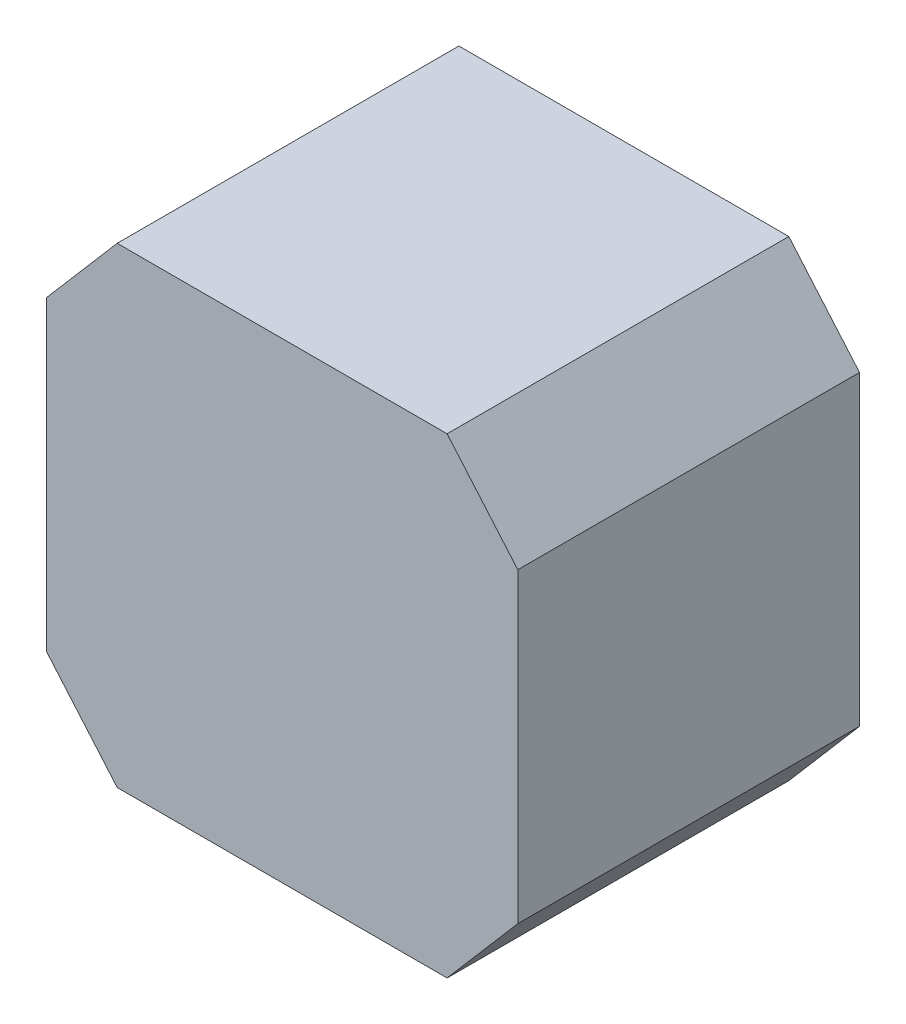
from build123d import *

# Parameters (mm, degrees)
SALIENTE_EXTRUIR1_DEPTH = 29


with BuildPart() as part:
    # Croquis2 → Saliente-Extruir1 (new body)
    with BuildSketch(Plane.XY):
        Polygon((-14, 20.322580645), (14, 20.322580645), (20, 13.327514754), (20, -12.682353464), (14, -19.677419355), (-14, -19.677419355), (-20, -12.682353464), (-20, 13.327514754), align=None)
    extrude(amount=SALIENTE_EXTRUIR1_DEPTH)


solid = part.part
